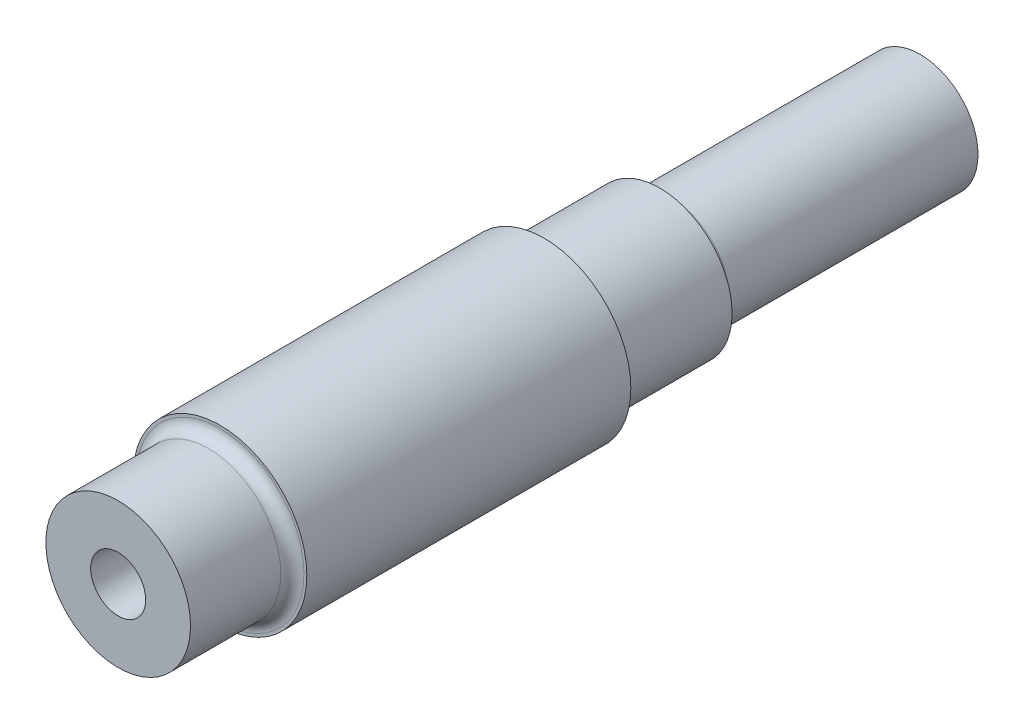
from build123d import *

# Parameters (mm, degrees)
SKETCH1_R           = 12.5
BOSS_EXTRUDE1_DEPTH = 93.6
SKETCH2_R           = 15
BOSS_EXTRUDE2_DEPTH = 56
SKETCH3_R           = 10
BOSS_EXTRUDE3_DEPTH = 45
SKETCH4_R           = 4.755
CUT_EXTRUDE1_DEPTH  = 60
FILLET2_R           = 2
FILLET3_R           = 1.5
FILLET4_R           = 2


with BuildPart() as part:
    # Sketch1 → Boss-Extrude1 (new body)
    with BuildSketch(Plane.XY):
        Circle(SKETCH1_R)
    extrude(amount=BOSS_EXTRUDE1_DEPTH)

    # Sketch2 → Boss-Extrude2 (add)
    with BuildSketch(Plane.XY.offset(76)):
        Circle(SKETCH2_R)
    extrude(amount=-BOSS_EXTRUDE2_DEPTH)

    # Sketch3 → Boss-Extrude3 (add)
    with BuildSketch(Plane(origin=(0, 0, 0), x_dir=(-1, 0, 0), z_dir=(0, 0, -1))):
        Circle(SKETCH3_R)
    extrude(amount=BOSS_EXTRUDE3_DEPTH)

    # Sketch4 → Cut-Extrude1 (cut)
    with BuildSketch(Plane.XY.offset(93.6)):
        Circle(SKETCH4_R)
    extrude(amount=-CUT_EXTRUDE1_DEPTH, mode=Mode.SUBTRACT)

    # Fillet2
    fillet2_edges = [part.edges().sort_by_distance(p)[0] for p in [
        (-12.5, 0, 76),
    ]]
    fillet(fillet2_edges, radius=FILLET2_R)

    # Fillet3
    fillet3_edges = [part.edges().sort_by_distance(p)[0] for p in [
        (-12.5, 0, 20),
    ]]
    fillet(fillet3_edges, radius=FILLET3_R)

    # Fillet4
    fillet4_edges = [part.edges().sort_by_distance(p)[0] for p in [
        (10, 0, 0),
    ]]
    fillet(fillet4_edges, radius=FILLET4_R)


solid = part.part
